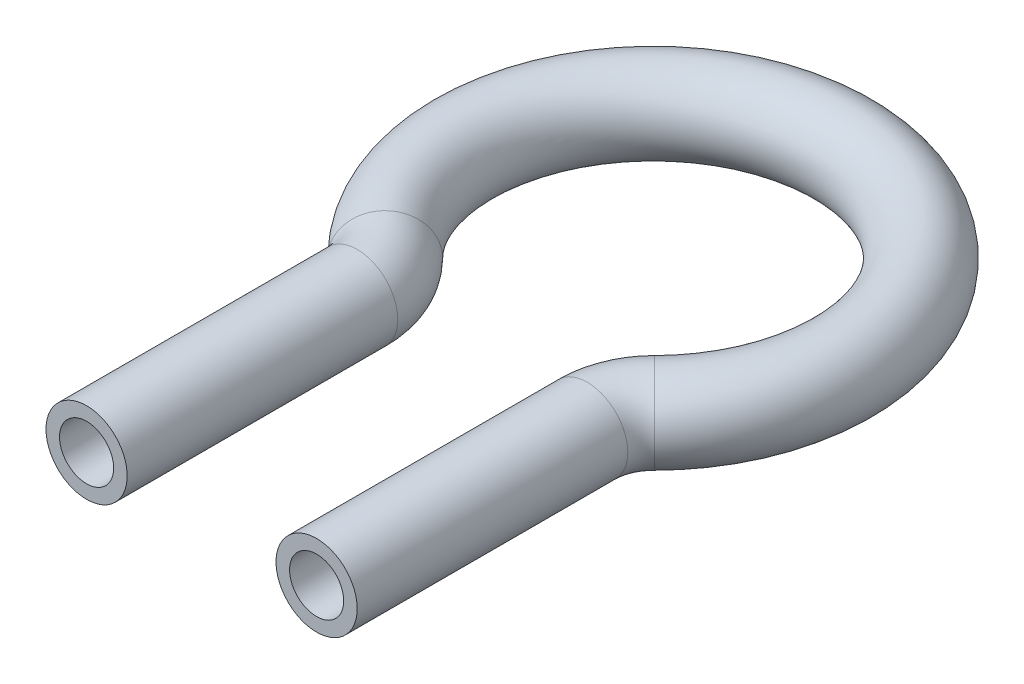
from build123d import *

# Parameters (mm, degrees)
SKETCH2_R   = 3
SKETCH2_R_2 = 2


with BuildPart() as part:
    # Sweep1: sweep along a path in Sketch1
    with BuildLine(Plane(origin=(0, 0, 0), x_dir=(1, 0, 0), z_dir=(0, 1, 0))) as sweep1_path:
        Line((8.5, -33.369741957), (8.5, -13.369741957))
        ThreePointArc((8.5, -13.369741957), (8.875978055, -11.467527181), (9.947368421, -9.851388811))
        ThreePointArc((9.947368421, -9.851388811), (0, 14), (-9.947368421, -9.851388811))
        ThreePointArc((-9.947368421, -9.851388811), (-8.875978055, -11.467527181), (-8.5, -13.369741957))
        Line((-8.5, -13.369741957), (-8.5, -33.369741957))
    # Sketch2 → Sweep1 (sweep)
    with BuildSketch(Plane(origin=(-8.5, 0, 33.369741957), x_dir=(-1, 0, 0), z_dir=(0, 0, -1))):
        Circle(SKETCH2_R)
        Circle(SKETCH2_R_2, mode=Mode.SUBTRACT)
    sweep(path=sweep1_path.line)


solid = part.part
